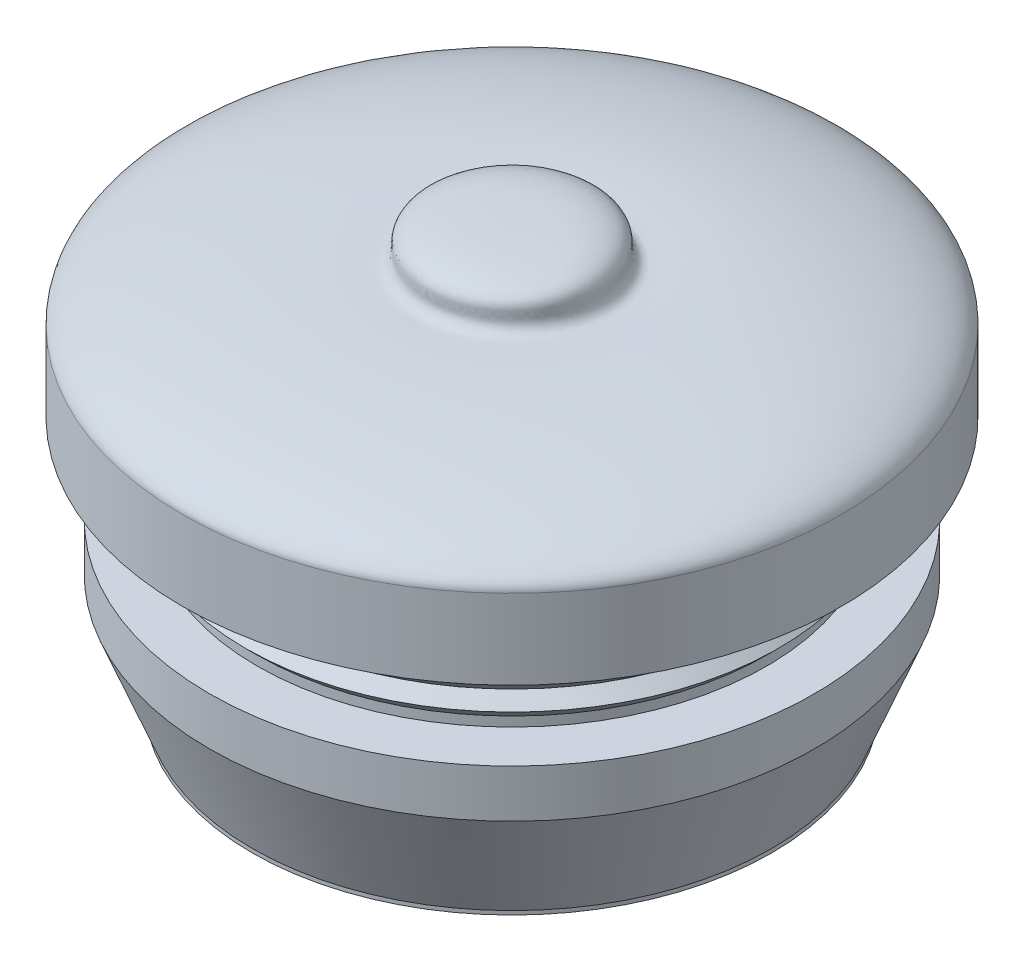
from build123d import *


with BuildPart() as part:
    # Sketch1 → Revolve1 (revolve)
    with BuildSketch(Plane(origin=(0, 0, 0), x_dir=(0, 0, -1), z_dir=(1, 0, 0))):
        with BuildLine():
            Line((-10.35, -0.083114039), (-10.35, 2.416885961))
            add(Edge.make_bspline(
                [(-10.35, 2.416885961), (-10.35, 3.365522707), (-5.87405228, 4.241080394), (-2.867984372, 4.033812591), (-2.611626956, 4.324223727), (-2.731131844, 4.758475996), (-2.197387439, 5.360223564), (-0.492736408, 5.316885961), (0, 5.316885961)],
                knots=[0, 0, 0, 0, 0.734908426, 0.759492363, 0.786959078, 0.823764272, 0.867168962, 1, 1, 1, 1], degree=3))
            Line((0, 5.316885961), (0, 3.882124351))
            Line((0, 3.882124351), (-1.400856338, 3.882124351))
            Line((-1.400856338, 3.882124351), (-1.400856338, 2.565845829))
            Line((-1.400856338, 2.565845829), (-6.683387829, 1.648087396))
            Line((-6.683387829, 1.648087396), (-6.683387829, -4.921019872))
            Line((-6.683387829, -4.921019872), (-3.287892009, -7.171193847))
            Line((-3.287892009, -7.171193847), (-3.759677095, -7.883114039))
            Line((-3.759677095, -7.883114039), (-7.30583237, -5.533098981))
            Line((-7.30583237, -5.533098981), (-7.30583237, -7.883114039))
            Line((-7.30583237, -7.883114039), (-8.159470598, -7.883114039))
            Line((-8.159470598, -7.883114039), (-8.159470598, -7.762098691))
            Line((-8.159470598, -7.762098691), (-9.5, -4.383114039))
            Line((-9.5, -4.383114039), (-9.5, -2.883114039))
            Line((-9.5, -2.883114039), (-8, -2.883114039))
            Line((-8, -2.883114039), (-8, -2.583114039))
            Line((-8, -2.583114039), (-8.366666667, -2.216447373))
            Line((-8.366666667, -2.216447373), (-8, -1.849780706))
            Line((-8, -1.849780706), (-8.366666667, -1.483114039))
            Line((-8.366666667, -1.483114039), (-8, -1.116447373))
            Line((-8, -1.116447373), (-8.366666667, -0.749780706))
            Line((-8.366666667, -0.749780706), (-8, -0.383114039))
            Line((-8, -0.383114039), (-8, -0.083114039))
            Line((-8, -0.083114039), (-10.35, -0.083114039))
        make_face()
    revolve(axis=Axis((0, 6.890935363, 0), (0, -1, 0)))


solid = part.part
